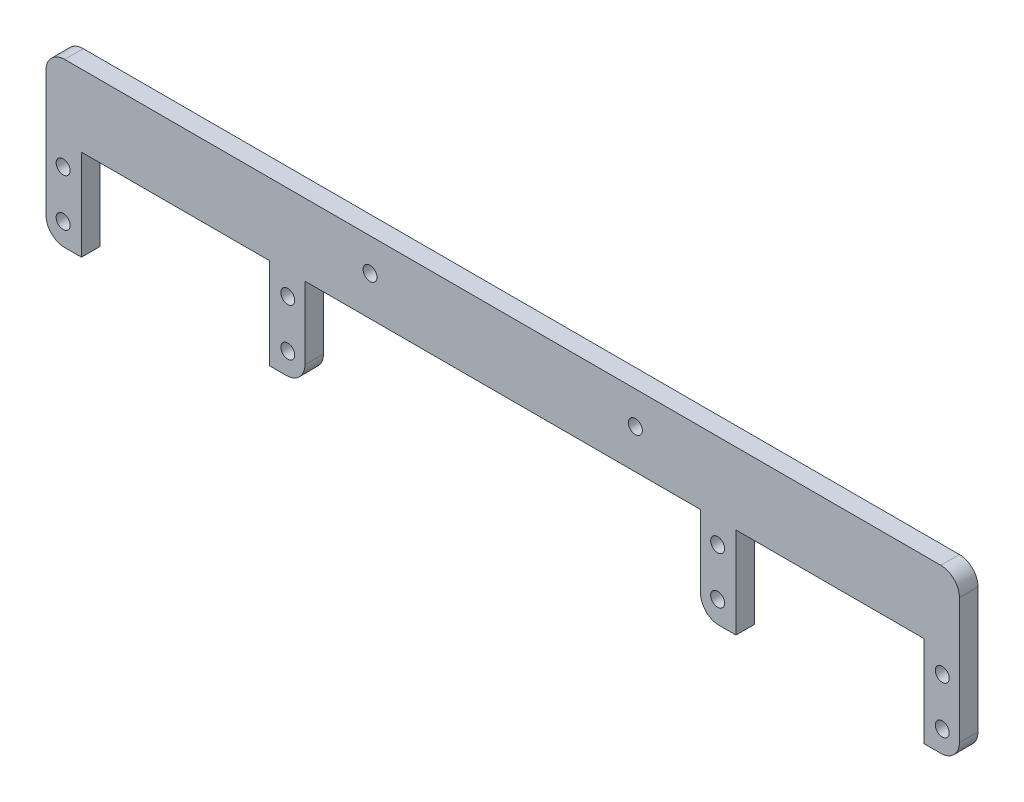
from build123d import *

# Parameters (mm, degrees)
BOSS_EXTRUDE2_DEPTH = 4
FILLET1_R           = 4
SKETCH6_R           = 1.5
CUT_EXTRUDE1_DEPTH  = 4
SKETCH3_R           = 1.5
CUT_EXTRUDE2_DEPTH  = 4


with BuildPart() as part:
    # Sketch2 → Boss-Extrude2 (new body)
    with BuildSketch(Plane.XY):
        Polygon((-67.081093968, -2.634474623), (-67.081093968, 16.923525377), (-26.695093968, 16.923525377), (-26.695093968, -2.634474623), (-19.075093968, -2.634474623), (-19.075093968, 32.365525377), (-67.081093968, 32.365525377), (-74.701093968, 32.365525377), (-159.701093968, 32.365525377), (-167.321093968, 32.365525377), (-215.327093968, 32.365525377), (-215.327093968, -2.634474623), (-207.707093968, -2.634474623), (-207.707093968, 16.923525377), (-167.321093968, 16.923525377), (-167.231910297, 16.736340115), (-167.321093968, 16.736752562), (-167.321093968, -2.634474623), (-159.701093968, -2.634474623), (-159.701093968, 16.923525377), (-74.701093968, 16.923525377), (-74.701093968, -2.634474623), align=None)
    extrude(amount=BOSS_EXTRUDE2_DEPTH)

    # Fillet1
    fillet1_edges = [part.edges().sort_by_distance(p)[0] for p in [
        (-19.075093968, 32.365525377, 2),
        (-19.075093968, -2.634474623, 2),
        (-74.701093968, -2.634474623, 2),
        (-159.701093968, -2.634474623, 2),
        (-215.327093968, -2.634474623, 2),
        (-215.327093968, 32.365525377, 2),
    ]]
    fillet(fillet1_edges, radius=FILLET1_R)

    # Sketch6 → Cut-Extrude1 (cut)
    with BuildSketch(Plane.XY.offset(4)):
        with Locations((-211.644093968, 12.224525377)):
            Circle(SKETCH6_R)
        with Locations((-163.384093968, 12.224525377)):
            Circle(SKETCH6_R)
        with Locations((-163.384093968, 2.064525377)):
            Circle(SKETCH6_R)
        with Locations((-211.644093968, 2.064525377)):
            Circle(SKETCH6_R)
        with Locations((-71.018093968, 12.224525377)):
            Circle(SKETCH6_R)
        with Locations((-22.758093968, 12.224525377)):
            Circle(SKETCH6_R)
        with Locations((-22.758093968, 2.064525377)):
            Circle(SKETCH6_R)
        with Locations((-71.018093968, 2.064525377)):
            Circle(SKETCH6_R)
    extrude(amount=-CUT_EXTRUDE1_DEPTH, mode=Mode.SUBTRACT)

    # Sketch3 → Cut-Extrude2 (cut)
    with BuildSketch(Plane.XY.offset(4)):
        with Locations((-145.701093968, 25.365525377)):
            Circle(SKETCH3_R)
        with Locations((-88.701093968, 25.365525377)):
            Circle(SKETCH3_R)
    extrude(amount=-CUT_EXTRUDE2_DEPTH, mode=Mode.SUBTRACT)


solid = part.part
